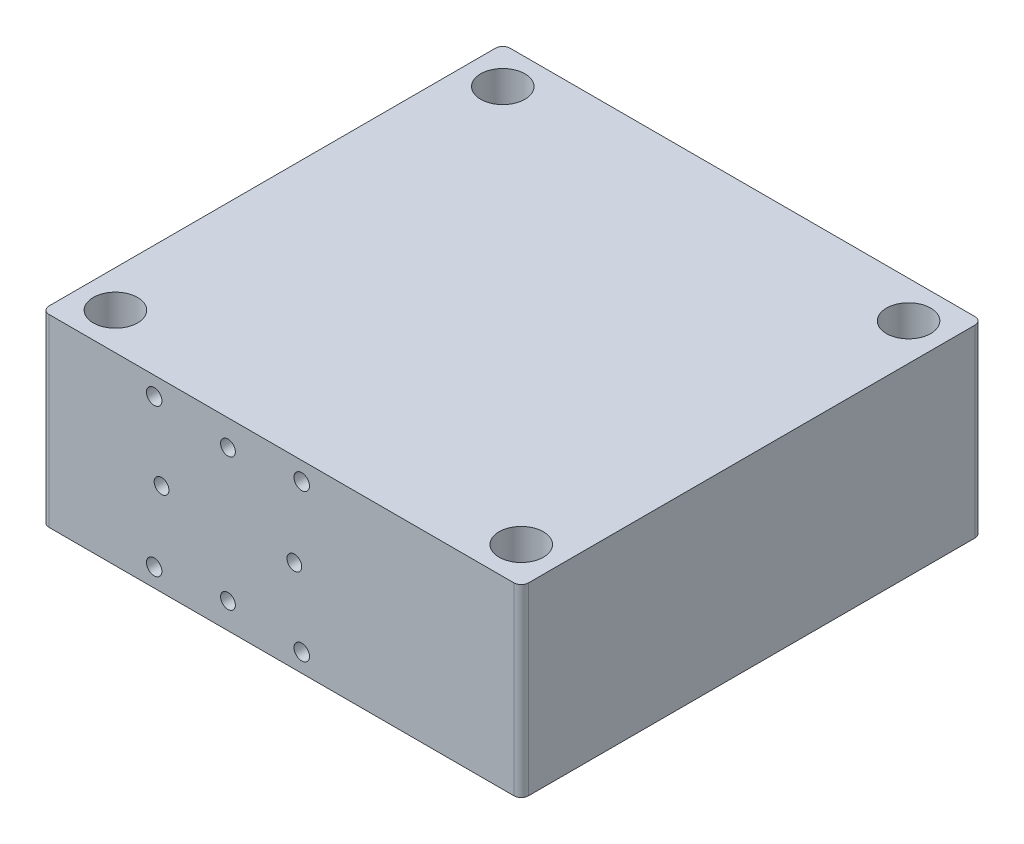
from build123d import *

# Parameters (mm, degrees)
SKETCH_1_W             = 130
SKETCH_1_H             = 125
EXTRUDE_1_DEPTH        = 50
SKETCH_2_R             = 6
CUT_EXTRUDE_1_DEPTH    = 51
FILLET_1_R             = 2
SKETCH_4_R             = 11.5
CUT_EXTRUDE_2_DEPTH    = 2
MM_4_D                 = 11
MM_4_DEPTH             = 25
MM_4_TIP               = 3.304733405
MM_4_2_D               = 11
MM_4_2_DEPTH           = 25
MM_4_2_TIP             = 3.304733405
HOLE_WIZARD_M5_1_D     = 4.2
HOLE_WIZARD_M5_1_DEPTH = 12
HOLE_WIZARD_M5_1_TIP   = 1.2618073
MM_3_D                 = 4
MM_3_DEPTH             = 56
MM_3_TIP               = 1.201721238
MM_4_3_D               = 4
MM_4_3_DEPTH           = 87
MM_4_3_TIP             = 1.201721238
MM_5_D                 = 4
M10X1_0_1_D            = 9
M10X1_0_1_DEPTH        = 14
M10X1_0_1_TIP          = 2.703872786


with BuildPart() as part:
    # 草图1 → 凸台-拉伸1 (new body)
    with BuildSketch(Plane(origin=(0, 0, 0), x_dir=(1, 0, 0), z_dir=(0, 1, 0))):
        Rectangle(SKETCH_1_W, SKETCH_1_H)
    extrude(amount=EXTRUDE_1_DEPTH)

    # 草图2 → 切除-拉伸1 (cut, through all)
    with BuildSketch(Plane(origin=(0, 50, 0), x_dir=(1, 0, 0), z_dir=(0, 1, 0))):
        with Locations((-55, 52.5)):
            Circle(SKETCH_2_R)
        with Locations((55, 52.5)):
            Circle(SKETCH_2_R)
        with Locations((55, -52.5)):
            Circle(SKETCH_2_R)
        with Locations((-55, -52.5)):
            Circle(SKETCH_2_R)
    extrude(amount=-CUT_EXTRUDE_1_DEPTH, mode=Mode.SUBTRACT)

    # 圆角1
    fillet_1_edges = [part.edges().sort_by_distance(p)[0] for p in [
        (65, 25, 62.5),
        (-65, 25, 62.5),
        (-65, 25, -62.5),
        (65, 25, -62.5),
    ]]
    fillet(fillet_1_edges, radius=FILLET_1_R)

    # 草图4 → 切除-拉伸2 (cut)
    with BuildSketch(Plane.XZ):
        with Locations((-35, -27.5)):
            Circle(SKETCH_4_R)
        with Locations((5, 2.5)):
            Circle(SKETCH_4_R)
    extrude(amount=-CUT_EXTRUDE_2_DEPTH, mode=Mode.SUBTRACT)

    # mm _4
    with Locations(Plane(origin=(0, 2, 0), x_dir=(-1, 0, 0), z_dir=(0, -1, 0))):
        with Locations((-5, -2.5)):
            Hole(MM_4_D / 2, depth=MM_4_DEPTH)
            with Locations((0, 0, -(MM_4_DEPTH + MM_4_TIP / 2))):  # 118° drill point
                Cone(0, MM_4_D / 2, MM_4_TIP, mode=Mode.SUBTRACT)

    # mm _4 2
    with Locations(Plane(origin=(0, 2, 0), x_dir=(-1, 0, 0), z_dir=(0, -1, 0))):
        with Locations((35, 27.5)):
            Hole(MM_4_2_D / 2, depth=MM_4_2_DEPTH)
            with Locations((0, 0, -(MM_4_2_DEPTH + MM_4_2_TIP / 2))):  # 118° drill point
                Cone(0, MM_4_2_D / 2, MM_4_2_TIP, mode=Mode.SUBTRACT)

    # M5 螺纹孔1
    with Locations(Plane.XY.offset(62.5)):
        with Locations((-34.5, 45), (5.5, 45), (5.5, 5), (-34.5, 5)):
            Hole(HOLE_WIZARD_M5_1_D / 2, depth=HOLE_WIZARD_M5_1_DEPTH)
            with Locations((0, 0, -(HOLE_WIZARD_M5_1_DEPTH + HOLE_WIZARD_M5_1_TIP / 2))):  # 118° drill point
                Cone(0, HOLE_WIZARD_M5_1_D / 2, HOLE_WIZARD_M5_1_TIP, mode=Mode.SUBTRACT)

    # 大小mm 暗销孔3
    with Locations(Plane.XY.offset(62.5)):
        with Locations((3.5, 25)):
            Hole(MM_3_D / 2, depth=MM_3_DEPTH)
            with Locations((0, 0, -(MM_3_DEPTH + MM_3_TIP / 2))):  # 118° drill point
                Cone(0, MM_3_D / 2, MM_3_TIP, mode=Mode.SUBTRACT)

    # mm _4 3
    with Locations(Plane.XY.offset(62.5)):
        with Locations((-32.5, 25)):
            Hole(MM_4_3_D / 2, depth=MM_4_3_DEPTH)
            with Locations((0, 0, -(MM_4_3_DEPTH + MM_4_3_TIP / 2))):  # 118° drill point
                Cone(0, MM_4_3_D / 2, MM_4_3_TIP, mode=Mode.SUBTRACT)

    # 大小mm 暗销孔5 (through all)
    with Locations(Plane.XY.offset(62.5)):
        with Locations((-14.5, 43), (-14.5, 7)):
            Hole(MM_5_D / 2)

    # M10x1.0 螺纹孔1
    with Locations(Plane(origin=(0, 0, -62.5), x_dir=(-1, 0, 0), z_dir=(0, 0, -1))):
        with Locations((14.5, 43), (14.5, 7)):
            Hole(M10X1_0_1_D / 2, depth=M10X1_0_1_DEPTH)
            with Locations((0, 0, -(M10X1_0_1_DEPTH + M10X1_0_1_TIP / 2))):  # 118° drill point
                Cone(0, M10X1_0_1_D / 2, M10X1_0_1_TIP, mode=Mode.SUBTRACT)


solid = part.part
